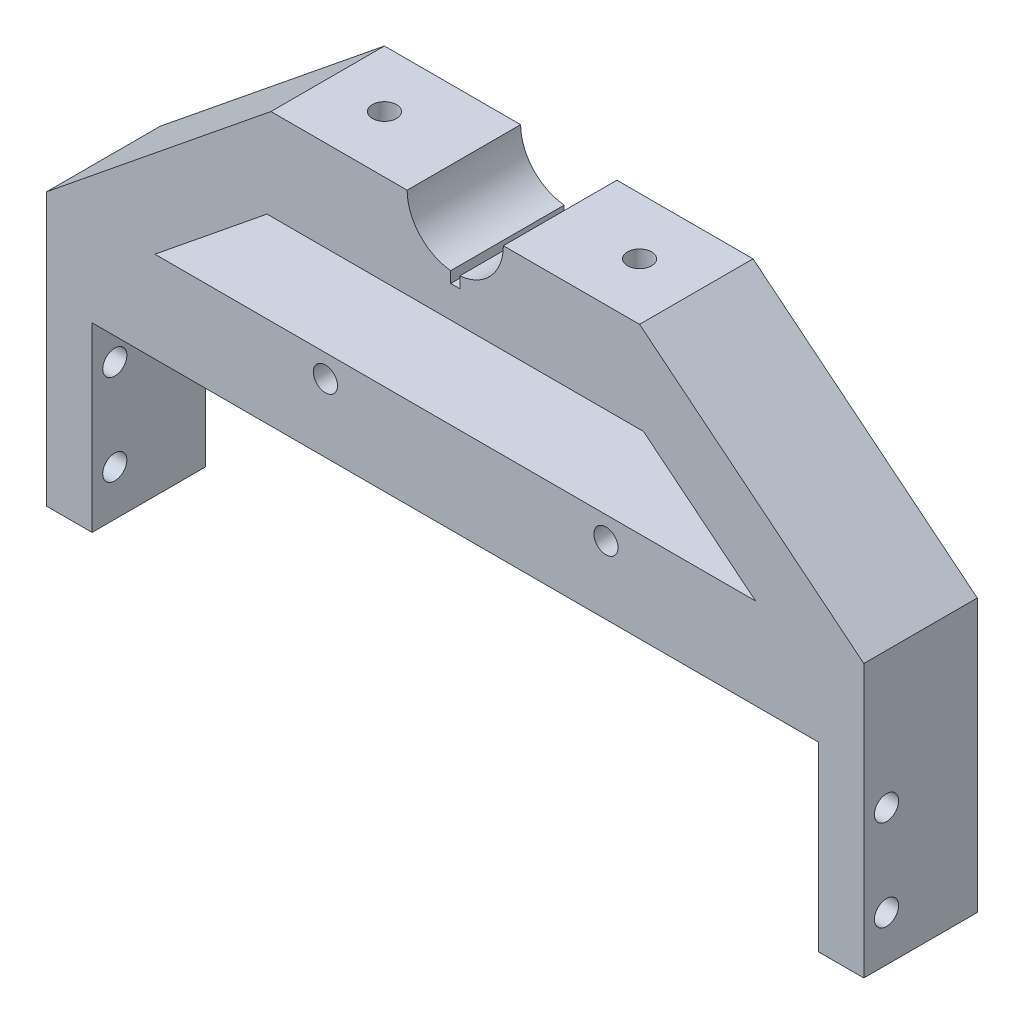
from build123d import *

# Parameters (mm, degrees)
BOSS_EXTRUDE1_DEPTH = 50.8
SKETCH3_R           = 3.3782
CUT_EXTRUDE1_DEPTH  = 25.4
SKETCH4_R           = 3.3782
CUT_EXTRUDE2_DEPTH  = 25.4
SKETCH7_W           = 279.740966103
SKETCH7_H           = 194.949015238
CUT_EXTRUDE5_DEPTH  = 19.05
SKETCH8_W           = 228.6
SKETCH8_H           = 25.4
CUT_EXTRUDE6_DEPTH  = 39.37
SKETCH9_R           = 3.3782
CUT_EXTRUDE7_DEPTH  = 27.94
CUT_EXTRUDE8_DEPTH  = 40.64
SKETCH12_W          = 1.27
SKETCH12_H          = 31.75
CUT_EXTRUDE9_DEPTH  = 16.51
CUT_EXTRUDE10_REACH = 33.75
SKETCH13_R          = 3.3782


with BuildPart() as part:
    # Sketch2 → Boss-Extrude1 (new body)
    with BuildSketch(Plane.XY):
        with BuildLine():
            Line((254, 0), (266.7, 0))
            Line((266.7, 0), (266.7, 101.6))
            Line((266.7, 101.6), (203.962, 152.4))
            Line((203.962, 152.4), (165.862, 152.4))
            ThreePointArc((165.862, 152.4), (152.4, 138.938), (138.938, 152.4))
            Line((138.938, 152.4), (100.838, 152.4))
            Line((100.838, 152.4), (38.1, 101.6))
            Line((38.1, 101.6), (38.1, 0))
            Line((38.1, 0), (50.8, 0))
            Line((50.8, 0), (50.8, 76.2))
            Line((50.8, 76.2), (254, 76.2))
            Line((254, 76.2), (254, 0))
        make_face()
    extrude(amount=BOSS_EXTRUDE1_DEPTH)

    # Sketch3 → Cut-Extrude1 (cut)
    with BuildSketch(Plane.ZY.offset(-38.1)):
        with Locations((25.4, 63.5)):
            Circle(SKETCH3_R)
        with Locations((25.4, 38.1)):
            Circle(SKETCH3_R)
    extrude(amount=-CUT_EXTRUDE1_DEPTH, mode=Mode.SUBTRACT)

    # Sketch4 → Cut-Extrude2 (cut)
    with BuildSketch(Plane(origin=(266.7, 0, 0), x_dir=(0, 0, -1), z_dir=(1, 0, 0))):
        with Locations((-25.4, 63.5)):
            Circle(SKETCH4_R)
        with Locations((-25.4, 38.1)):
            Circle(SKETCH4_R)
    extrude(amount=-CUT_EXTRUDE2_DEPTH, mode=Mode.SUBTRACT)

    # Sketch7 → Cut-Extrude5 (cut)
    with BuildSketch(Plane.XY.offset(50.8)):
        with Locations((152.037641236, 76.2)):
            Rectangle(SKETCH7_W, SKETCH7_H)
    extrude(amount=-CUT_EXTRUDE5_DEPTH, mode=Mode.SUBTRACT)

    # Sketch8 → Cut-Extrude6 (cut)
    with BuildSketch(Plane.XY.offset(31.75)):
        with Locations((152.4, 12.7)):
            Rectangle(SKETCH8_W, SKETCH8_H)
    extrude(amount=-CUT_EXTRUDE6_DEPTH, mode=Mode.SUBTRACT)

    # Sketch9 → Cut-Extrude7 (cut)
    with BuildSketch(Plane(origin=(0, 152.4, 0), x_dir=(1, 0, 0), z_dir=(0, 1, 0))):
        with Locations((116.713, -15.875)):
            Circle(SKETCH9_R)
        with Locations((188.087, -15.875)):
            Circle(SKETCH9_R)
    extrude(amount=-CUT_EXTRUDE7_DEPTH, mode=Mode.SUBTRACT)

    # Sketch10 → Cut-Extrude8 (cut)
    with BuildSketch(Plane.XY.offset(31.75)):
        Polygon((68.372272223, 101.6), (99.741272223, 127), (205.058727777, 127), (236.427727777, 101.6), align=None)
    extrude(amount=-CUT_EXTRUDE8_DEPTH, mode=Mode.SUBTRACT)

    # Sketch12 → Cut-Extrude9 (cut)
    with BuildSketch(Plane(origin=(0, 152.4, 0), x_dir=(1, 0, 0), z_dir=(0, 1, 0))):
        with Locations((153.035, -15.875)):
            Rectangle(SKETCH12_W, SKETCH12_H)
        with Locations((151.765, -15.875)):
            Rectangle(SKETCH12_W, SKETCH12_H)
    extrude(amount=-CUT_EXTRUDE9_DEPTH, mode=Mode.SUBTRACT)

    # Sketch13 → Cut-Extrude10 (cut, up to next)
    with BuildSketch(Plane.XY.offset(31.75), mode=Mode.PRIVATE) as cut_extrude10_sk1:
        with Locations((116.078, 95.25)):
            Circle(SKETCH13_R)
    cut_extrude10_tool1 = extrude(cut_extrude10_sk1.sketch, amount=-CUT_EXTRUDE10_REACH, mode=Mode.PRIVATE) & part.part
    add(cut_extrude10_tool1.solids().sort_by_distance((116.078, 95.25, 31.75))[0], mode=Mode.SUBTRACT)
    # Sketch13 → Cut-Extrude10 (cut, up to next)
    with BuildSketch(Plane.XY.offset(31.75), mode=Mode.PRIVATE) as cut_extrude10_sk2:
        with Locations((194.564, 95.25)):
            Circle(SKETCH13_R)
    cut_extrude10_tool2 = extrude(cut_extrude10_sk2.sketch, amount=-CUT_EXTRUDE10_REACH, mode=Mode.PRIVATE) & part.part
    add(cut_extrude10_tool2.solids().sort_by_distance((194.564, 95.25, 31.75))[0], mode=Mode.SUBTRACT)


solid = part.part
